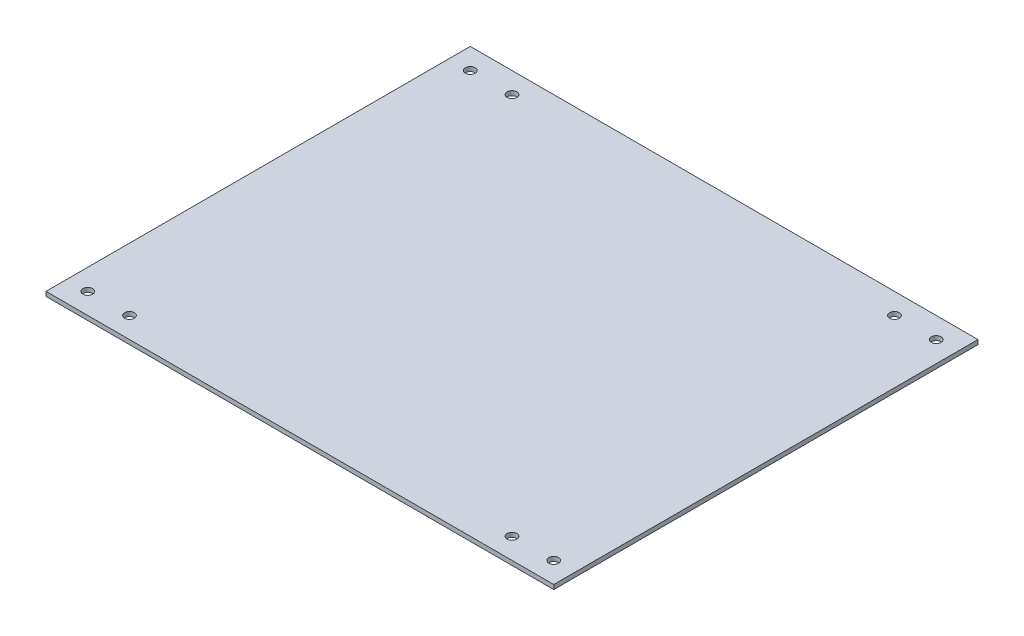
from build123d import *

# Parameters (mm, degrees)
SKETCH1_W           = 364.8
SKETCH1_H           = 304.8
BOSS_EXTRUDE1_DEPTH = 3.175
HOLE1_D             = 7


with BuildPart() as part:
    # Sketch1 → Boss-Extrude1 (new body)
    with BuildSketch(Plane(origin=(0, 0, 0), x_dir=(1, 0, 0), z_dir=(0, 1, 0))):
        with Locations((182.4, 152.4)):
            Rectangle(SKETCH1_W, SKETCH1_H)
    extrude(amount=BOSS_EXTRUDE1_DEPTH)

    # Hole1 (through all)
    with Locations(Plane(origin=(0, 3.175, 0), x_dir=(1, 0, 0), z_dir=(0, 1, 0))):
        with Locations((45, 15), (15, 289.8), (349.8, 289.8), (349.8, 15), (15, 15), (45, 289.8), (319.8, 289.8), (319.8, 15)):
            Hole(HOLE1_D / 2)


solid = part.part
